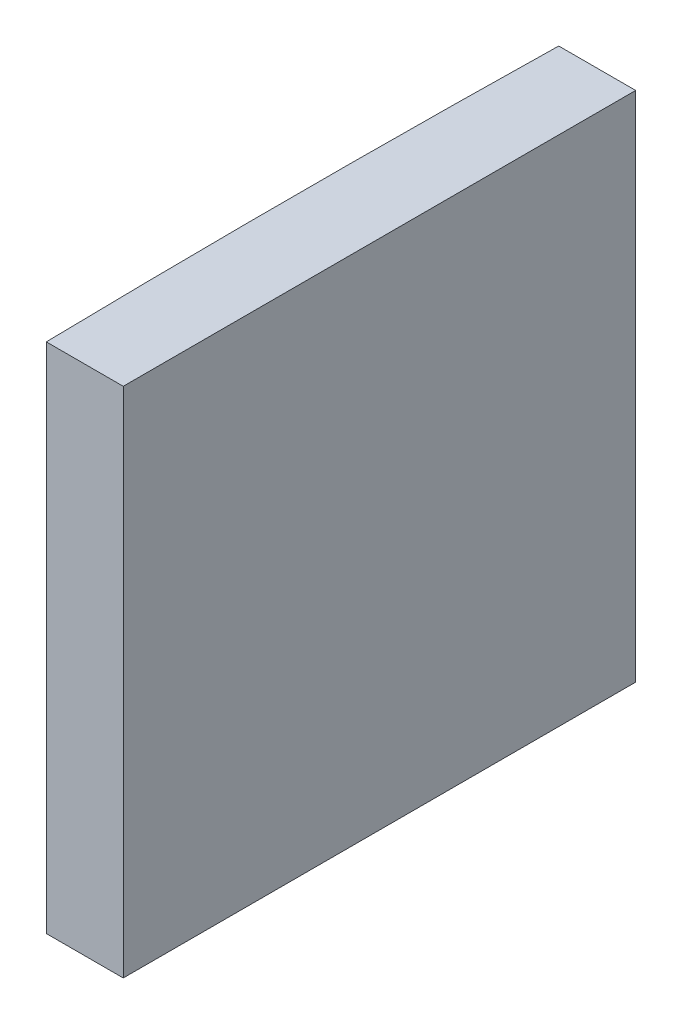
from build123d import *

# Parameters (mm, degrees)
EXTRUDE_1_DEPTH = 20


with BuildPart() as part:
    # 草图1 → 凸台-拉伸1 (new body)
    with BuildSketch(Plane(origin=(0, 0, 0), x_dir=(1, 0, 0), z_dir=(0, 1, 0))):
        with BuildLine():
            Line((-512.348037381, 10), (-509.344795665, 10))
            Line((-509.344795665, 10), (-509.344795665, -10))
            Line((-509.344795665, -10), (-512.348037381, -10))
            ThreePointArc((-512.348037381, -10), (-512.444795665, 0), (-512.348037381, 10))
        make_face()
    extrude(amount=EXTRUDE_1_DEPTH)


solid = part.part
